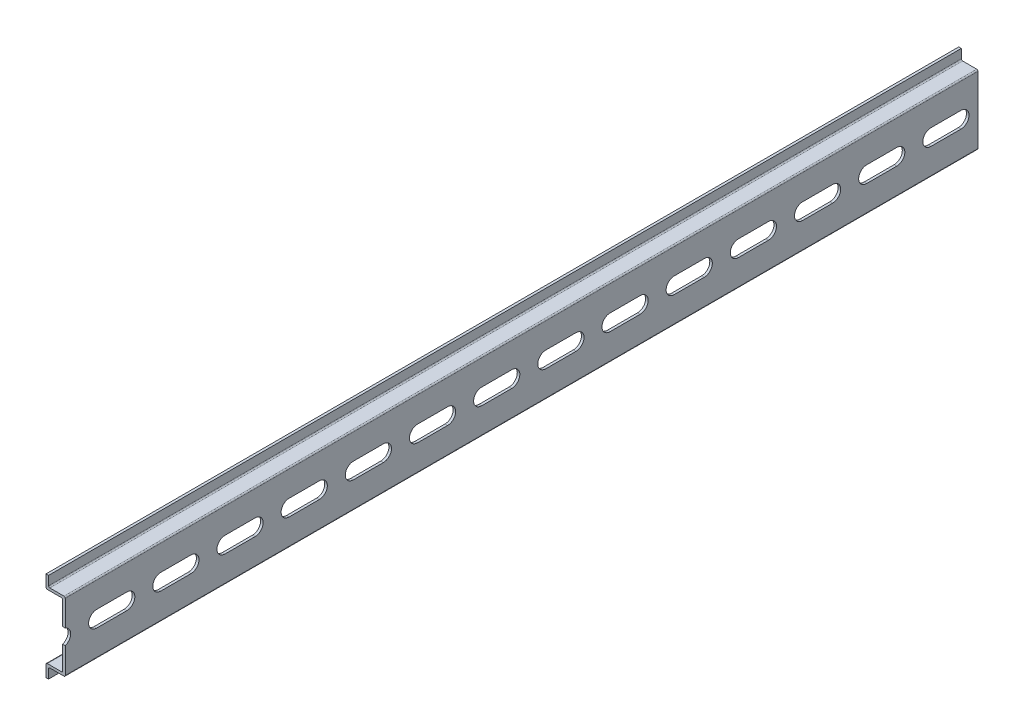
from build123d import *

# Parameters (mm, degrees)
EXTRUDE_THIN1_DEPTH = 449.2625
CUT_EXTRUDE1_START  = -8.5
CUT_EXTRUDE1_DEPTH  = 9.5
LPATTERN1_COUNT     = 18
LPATTERN1_PITCH     = 25
FILLET1_R           = 0.5
SKETCH5_W           = 14.543721181
SKETCH5_H           = 38.348187902
CUT_EXTRUDE2_DEPTH  = 93.6625


with BuildPart() as part:
    # Sketch3 → Extrude-Thin1 (new body)
    with BuildSketch(Plane.XY):
        Polygon((-6.5, 17.5), (-6.5, 13.5), (0, 13.5), (0, -13.5), (-6.5, -13.5), (-6.5, -17.5), (-7.5, -17.5), (-7.5, -12.5), (-1, -12.5), (-1, 12.5), (-7.5, 12.5), (-7.5, 17.5), align=None)
    extrude(amount=EXTRUDE_THIN1_DEPTH)

    # Sketch4 → Cut-Extrude1 (cut)
    with BuildSketch(Plane(origin=(0, 0, 0), x_dir=(0, 0, -1), z_dir=(1, 0, 0)).offset(CUT_EXTRUDE1_START)):
        with BuildLine():
            Line((-6.65, -3.15), (-18.35, -3.15))
            ThreePointArc((-18.35, -3.15), (-21.5, 0), (-18.35, 3.15))
            Line((-18.35, 3.15), (-6.65, 3.15))
            ThreePointArc((-6.65, 3.15), (-3.5, 0), (-6.65, -3.15))
        make_face()
    cut_extrude1 = extrude(amount=CUT_EXTRUDE1_DEPTH, mode=Mode.SUBTRACT)

    # LPattern1: Cut-Extrude1 ×18
    with Locations(*[(0, 0, i * LPATTERN1_PITCH) for i in range(1, LPATTERN1_COUNT)]):
        add(cut_extrude1, mode=Mode.SUBTRACT)

    # Fillet1
    fillet1_edges = [part.edges().sort_by_distance(p)[0] for p in [
        (-6.5, 13.5, 224.63125),
        (0, 13.5, 224.63125),
        (0, -13.5, 224.63125),
        (-6.5, -13.5, 224.63125),
        (-7.5, -12.5, 224.63125),
        (-1, -12.5, 224.63125),
        (-1, 12.5, 224.63125),
        (-7.5, 12.5, 224.63125),
    ]]
    fillet(fillet1_edges, radius=FILLET1_R)

    # Sketch5 → Cut-Extrude2 (cut)
    with BuildSketch(Plane.XY.offset(449.2625)):
        with Locations((-3.04454966, -0.3205253)):
            Rectangle(SKETCH5_W, SKETCH5_H)
    extrude(amount=-CUT_EXTRUDE2_DEPTH, mode=Mode.SUBTRACT)


solid = part.part
